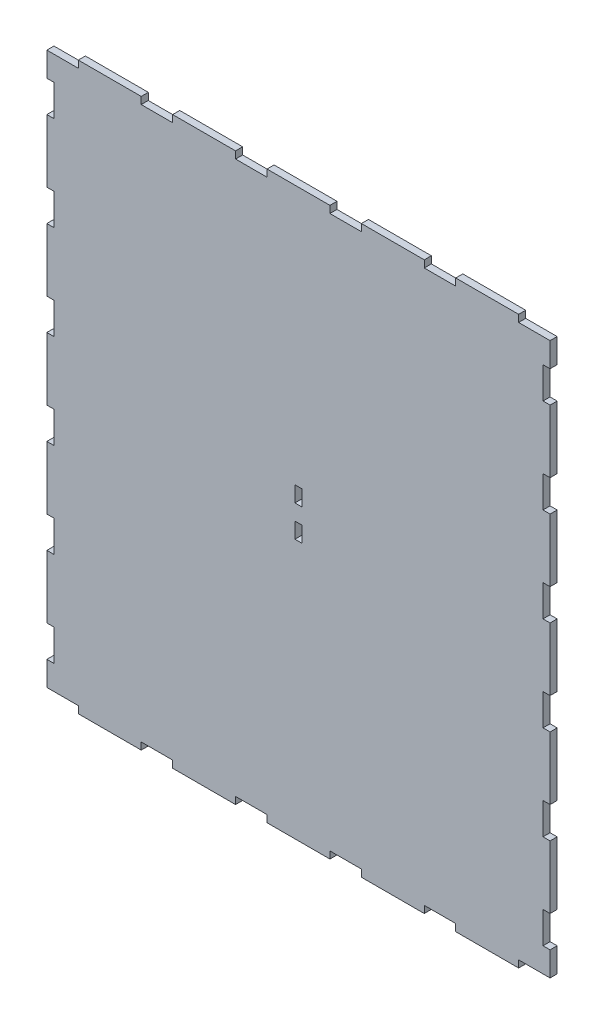
from build123d import *

# Parameters (mm, degrees)
SKETCH1_W                = 406.4
SKETCH1_H                = 457.2
BOSS_EXTRUDE1_DEPTH      = 5.715
SKETCH4_W                = 25.4
SKETCH4_H                = 5.715
FRONT_JIGSAW_DEPTH       = 6.715
SKETCH5_W                = 5.715
SKETCH5_H                = 25.4
RIGHT_JIGSAW_DEPTH       = 6.715
SKETCH7_W                = 5.715
SKETCH7_H                = 12.7
CENTER_SUPPORT_JIG_DEPTH = 6.715


with BuildPart() as part:
    # Sketch1 → Boss-Extrude1 (new body)
    with BuildSketch(Plane.XY):
        Rectangle(SKETCH1_W, SKETCH1_H)
    extrude(amount=BOSS_EXTRUDE1_DEPTH)

    # Sketch4 → Front Jigsaw (cut, through all)
    with BuildSketch(Plane(origin=(0, 0, 0), x_dir=(-1, 0, 0), z_dir=(0, 0, -1))):
        with Locations((-114.3, -225.7425)):
            Rectangle(SKETCH4_W, SKETCH4_H)
        with Locations((-190.5, -225.7425)):
            Rectangle(SKETCH4_W, SKETCH4_H)
        with Locations((-38.1, -225.7425)):
            Rectangle(SKETCH4_W, SKETCH4_H)
        with Locations((38.1, -225.7425)):
            Rectangle(SKETCH4_W, SKETCH4_H)
        with Locations((114.3, -225.7425)):
            Rectangle(SKETCH4_W, SKETCH4_H)
        with Locations((190.5, -225.7425)):
            Rectangle(SKETCH4_W, SKETCH4_H)
    front_jigsaw = extrude(amount=-FRONT_JIGSAW_DEPTH, mode=Mode.SUBTRACT)

    # Back Jigsaw: Front Jigsaw across plane
    add(front_jigsaw.mirror(Plane.ZX), mode=Mode.SUBTRACT)

    # Sketch5 → Right Jigsaw (cut, through all)
    with BuildSketch(Plane(origin=(0, 0, 0), x_dir=(-1, 0, 0), z_dir=(0, 0, -1))):
        with Locations((200.3425, 190.5)):
            Rectangle(SKETCH5_W, SKETCH5_H)
        with Locations((200.3425, 114.3)):
            Rectangle(SKETCH5_W, SKETCH5_H)
        with Locations((200.3425, 38.1)):
            Rectangle(SKETCH5_W, SKETCH5_H)
        with Locations((200.3425, -38.1)):
            Rectangle(SKETCH5_W, SKETCH5_H)
        with Locations((200.3425, -114.3)):
            Rectangle(SKETCH5_W, SKETCH5_H)
        with Locations((200.3425, -190.5)):
            Rectangle(SKETCH5_W, SKETCH5_H)
    right_jigsaw = extrude(amount=-RIGHT_JIGSAW_DEPTH, mode=Mode.SUBTRACT)

    # Left Jigsaw: Right Jigsaw across plane
    add(right_jigsaw.mirror(Plane(origin=(0, 0, 0), x_dir=(0, 0, 1), z_dir=(1, 0, 0))), mode=Mode.SUBTRACT)

    # Sketch7 → Center Support Jig (cut, through all)
    with BuildSketch(Plane(origin=(0, 0, 0), x_dir=(-1, 0, 0), z_dir=(0, 0, -1))):
        with Locations((0, 12.7)):
            Rectangle(SKETCH7_W, SKETCH7_H)
        with Locations((0, -12.7)):
            Rectangle(SKETCH7_W, SKETCH7_H)
    extrude(amount=-CENTER_SUPPORT_JIG_DEPTH, mode=Mode.SUBTRACT)


solid = part.part
